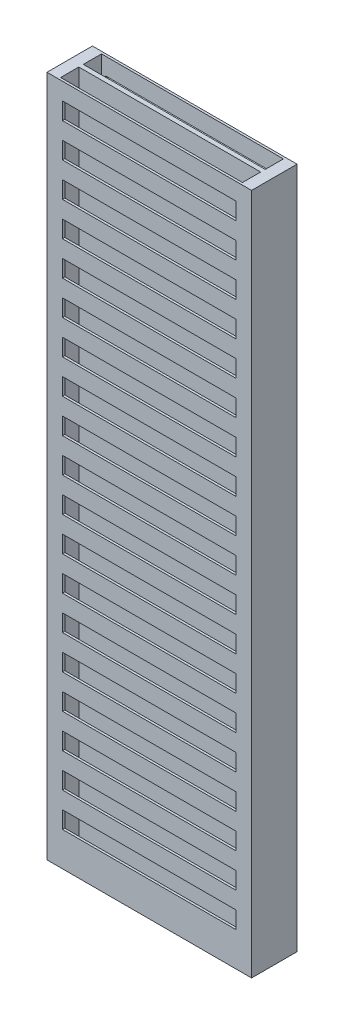
from build123d import *

# Parameters (mm, degrees)
SKETCH1_W                = 9
SKETCH1_H                = 2
BOSS_EXTRUDE1_DEPTH      = 15
CUT_EXTRUDE1_START       = -31
SKETCH2_W                = 8
SKETCH2_H                = 0.8
CUT_EXTRUDE1_DEPTH       = 32
SKETCH3_W                = 7.634272068
SKETCH3_H                = 0.75
CUT_EXTRUDE2_DEPTH       = 0.1
LPATTERN1_COUNT          = 19
LPATTERN1_PITCH          = 1.5
MIRROR2_COPY_1_SKETCH_W  = 7.634272068
MIRROR2_COPY_1_SKETCH_H  = 0.75
MIRROR2_COPY_1_DEPTH     = 0.1
MIRROR2_COPY_2_SKETCH_W  = 7.634272068
MIRROR2_COPY_2_SKETCH_H  = 0.75
MIRROR2_COPY_2_DEPTH     = 0.1
MIRROR2_COPY_3_SKETCH_W  = 7.634272068
MIRROR2_COPY_3_SKETCH_H  = 0.75
MIRROR2_COPY_3_DEPTH     = 0.1
MIRROR2_COPY_4_SKETCH_W  = 7.634272068
MIRROR2_COPY_4_SKETCH_H  = 0.75
MIRROR2_COPY_4_DEPTH     = 0.1
MIRROR2_COPY_5_SKETCH_W  = 7.634272068
MIRROR2_COPY_5_SKETCH_H  = 0.75
MIRROR2_COPY_5_DEPTH     = 0.1
MIRROR2_COPY_6_SKETCH_W  = 7.634272068
MIRROR2_COPY_6_SKETCH_H  = 0.75
MIRROR2_COPY_6_DEPTH     = 0.1
MIRROR2_COPY_7_SKETCH_W  = 7.634272068
MIRROR2_COPY_7_SKETCH_H  = 0.75
MIRROR2_COPY_7_DEPTH     = 0.1
MIRROR2_COPY_8_SKETCH_W  = 7.634272068
MIRROR2_COPY_8_SKETCH_H  = 0.75
MIRROR2_COPY_8_DEPTH     = 0.1
MIRROR2_COPY_9_SKETCH_W  = 7.634272068
MIRROR2_COPY_9_SKETCH_H  = 0.75
MIRROR2_COPY_9_DEPTH     = 0.1
MIRROR2_COPY_10_SKETCH_W = 7.634272068
MIRROR2_COPY_10_SKETCH_H = 0.75
MIRROR2_COPY_10_DEPTH    = 0.1
MIRROR2_COPY_11_SKETCH_W = 7.634272068
MIRROR2_COPY_11_SKETCH_H = 0.75
MIRROR2_COPY_11_DEPTH    = 0.1
MIRROR2_COPY_12_SKETCH_W = 7.634272068
MIRROR2_COPY_12_SKETCH_H = 0.75
MIRROR2_COPY_12_DEPTH    = 0.1
MIRROR2_COPY_13_SKETCH_W = 7.634272068
MIRROR2_COPY_13_SKETCH_H = 0.75
MIRROR2_COPY_13_DEPTH    = 0.1
MIRROR2_COPY_14_SKETCH_W = 7.634272068
MIRROR2_COPY_14_SKETCH_H = 0.75
MIRROR2_COPY_14_DEPTH    = 0.1
MIRROR2_COPY_15_SKETCH_W = 7.634272068
MIRROR2_COPY_15_SKETCH_H = 0.75
MIRROR2_COPY_15_DEPTH    = 0.1
MIRROR2_COPY_16_SKETCH_W = 7.634272068
MIRROR2_COPY_16_SKETCH_H = 0.75
MIRROR2_COPY_16_DEPTH    = 0.1
MIRROR2_COPY_17_SKETCH_W = 7.634272068
MIRROR2_COPY_17_SKETCH_H = 0.75
MIRROR2_COPY_17_DEPTH    = 0.1
MIRROR2_COPY_18_SKETCH_W = 7.634272068
MIRROR2_COPY_18_SKETCH_H = 0.75
MIRROR2_COPY_18_DEPTH    = 0.1


with BuildPart() as part:
    # Sketch1 → Boss-Extrude1 (new body, symmetric)
    with BuildSketch(Plane(origin=(0, 0, 0), x_dir=(1, 0, 0), z_dir=(0, 1, 0))):
        Rectangle(SKETCH1_W, SKETCH1_H)
    extrude(amount=BOSS_EXTRUDE1_DEPTH, both=True)

    # Sketch2 → Cut-Extrude1 (cut)
    with BuildSketch(Plane(origin=(0, 15, 0), x_dir=(1, 0, 0), z_dir=(0, 1, 0)).offset(CUT_EXTRUDE1_START)):
        with Locations((0, 0.5)):
            Rectangle(SKETCH2_W, SKETCH2_H)
    cut_extrude1 = extrude(amount=CUT_EXTRUDE1_DEPTH, mode=Mode.SUBTRACT)

    # Mirror1: Cut-Extrude1 across plane
    add(cut_extrude1.mirror(Plane.XY), mode=Mode.SUBTRACT)

    # Sketch3 → Cut-Extrude2 (cut)
    with BuildSketch(Plane.XY.offset(1)):
        with Locations((0, 13.875)):
            Rectangle(SKETCH3_W, SKETCH3_H)
    cut_extrude2 = extrude(amount=-CUT_EXTRUDE2_DEPTH, mode=Mode.SUBTRACT)

    # LPattern1: Cut-Extrude2 ×19
    with Locations(*[(0, -i * LPATTERN1_PITCH, 0) for i in range(1, LPATTERN1_COUNT)]):
        add(cut_extrude2, mode=Mode.SUBTRACT)

    # Mirror2: Cut-Extrude2 across plane
    add(cut_extrude2.mirror(Plane.XY), mode=Mode.SUBTRACT)

    # Mirror2 copy 1 sketch → Mirror2 copy 1 (cut)
    with BuildSketch(Plane(origin=(0, -1.5, -1), x_dir=(1, 0, 0), z_dir=(0, 0, -1))):
        with Locations((0, -13.875)):
            Rectangle(MIRROR2_COPY_1_SKETCH_W, MIRROR2_COPY_1_SKETCH_H)
    extrude(amount=-MIRROR2_COPY_1_DEPTH, mode=Mode.SUBTRACT)

    # Mirror2 copy 2 sketch → Mirror2 copy 2 (cut)
    with BuildSketch(Plane(origin=(0, -3, -1), x_dir=(1, 0, 0), z_dir=(0, 0, -1))):
        with Locations((0, -13.875)):
            Rectangle(MIRROR2_COPY_2_SKETCH_W, MIRROR2_COPY_2_SKETCH_H)
    extrude(amount=-MIRROR2_COPY_2_DEPTH, mode=Mode.SUBTRACT)

    # Mirror2 copy 3 sketch → Mirror2 copy 3 (cut)
    with BuildSketch(Plane(origin=(0, -4.5, -1), x_dir=(1, 0, 0), z_dir=(0, 0, -1))):
        with Locations((0, -13.875)):
            Rectangle(MIRROR2_COPY_3_SKETCH_W, MIRROR2_COPY_3_SKETCH_H)
    extrude(amount=-MIRROR2_COPY_3_DEPTH, mode=Mode.SUBTRACT)

    # Mirror2 copy 4 sketch → Mirror2 copy 4 (cut)
    with BuildSketch(Plane(origin=(0, -6, -1), x_dir=(1, 0, 0), z_dir=(0, 0, -1))):
        with Locations((0, -13.875)):
            Rectangle(MIRROR2_COPY_4_SKETCH_W, MIRROR2_COPY_4_SKETCH_H)
    extrude(amount=-MIRROR2_COPY_4_DEPTH, mode=Mode.SUBTRACT)

    # Mirror2 copy 5 sketch → Mirror2 copy 5 (cut)
    with BuildSketch(Plane(origin=(0, -7.5, -1), x_dir=(1, 0, 0), z_dir=(0, 0, -1))):
        with Locations((0, -13.875)):
            Rectangle(MIRROR2_COPY_5_SKETCH_W, MIRROR2_COPY_5_SKETCH_H)
    extrude(amount=-MIRROR2_COPY_5_DEPTH, mode=Mode.SUBTRACT)

    # Mirror2 copy 6 sketch → Mirror2 copy 6 (cut)
    with BuildSketch(Plane(origin=(0, -9, -1), x_dir=(1, 0, 0), z_dir=(0, 0, -1))):
        with Locations((0, -13.875)):
            Rectangle(MIRROR2_COPY_6_SKETCH_W, MIRROR2_COPY_6_SKETCH_H)
    extrude(amount=-MIRROR2_COPY_6_DEPTH, mode=Mode.SUBTRACT)

    # Mirror2 copy 7 sketch → Mirror2 copy 7 (cut)
    with BuildSketch(Plane(origin=(0, -10.5, -1), x_dir=(1, 0, 0), z_dir=(0, 0, -1))):
        with Locations((0, -13.875)):
            Rectangle(MIRROR2_COPY_7_SKETCH_W, MIRROR2_COPY_7_SKETCH_H)
    extrude(amount=-MIRROR2_COPY_7_DEPTH, mode=Mode.SUBTRACT)

    # Mirror2 copy 8 sketch → Mirror2 copy 8 (cut)
    with BuildSketch(Plane(origin=(0, -12, -1), x_dir=(1, 0, 0), z_dir=(0, 0, -1))):
        with Locations((0, -13.875)):
            Rectangle(MIRROR2_COPY_8_SKETCH_W, MIRROR2_COPY_8_SKETCH_H)
    extrude(amount=-MIRROR2_COPY_8_DEPTH, mode=Mode.SUBTRACT)

    # Mirror2 copy 9 sketch → Mirror2 copy 9 (cut)
    with BuildSketch(Plane(origin=(0, -13.5, -1), x_dir=(1, 0, 0), z_dir=(0, 0, -1))):
        with Locations((0, -13.875)):
            Rectangle(MIRROR2_COPY_9_SKETCH_W, MIRROR2_COPY_9_SKETCH_H)
    extrude(amount=-MIRROR2_COPY_9_DEPTH, mode=Mode.SUBTRACT)

    # Mirror2 copy 10 sketch → Mirror2 copy 10 (cut)
    with BuildSketch(Plane(origin=(0, -15, -1), x_dir=(1, 0, 0), z_dir=(0, 0, -1))):
        with Locations((0, -13.875)):
            Rectangle(MIRROR2_COPY_10_SKETCH_W, MIRROR2_COPY_10_SKETCH_H)
    extrude(amount=-MIRROR2_COPY_10_DEPTH, mode=Mode.SUBTRACT)

    # Mirror2 copy 11 sketch → Mirror2 copy 11 (cut)
    with BuildSketch(Plane(origin=(0, -16.5, -1), x_dir=(1, 0, 0), z_dir=(0, 0, -1))):
        with Locations((0, -13.875)):
            Rectangle(MIRROR2_COPY_11_SKETCH_W, MIRROR2_COPY_11_SKETCH_H)
    extrude(amount=-MIRROR2_COPY_11_DEPTH, mode=Mode.SUBTRACT)

    # Mirror2 copy 12 sketch → Mirror2 copy 12 (cut)
    with BuildSketch(Plane(origin=(0, -18, -1), x_dir=(1, 0, 0), z_dir=(0, 0, -1))):
        with Locations((0, -13.875)):
            Rectangle(MIRROR2_COPY_12_SKETCH_W, MIRROR2_COPY_12_SKETCH_H)
    extrude(amount=-MIRROR2_COPY_12_DEPTH, mode=Mode.SUBTRACT)

    # Mirror2 copy 13 sketch → Mirror2 copy 13 (cut)
    with BuildSketch(Plane(origin=(0, -19.5, -1), x_dir=(1, 0, 0), z_dir=(0, 0, -1))):
        with Locations((0, -13.875)):
            Rectangle(MIRROR2_COPY_13_SKETCH_W, MIRROR2_COPY_13_SKETCH_H)
    extrude(amount=-MIRROR2_COPY_13_DEPTH, mode=Mode.SUBTRACT)

    # Mirror2 copy 14 sketch → Mirror2 copy 14 (cut)
    with BuildSketch(Plane(origin=(0, -21, -1), x_dir=(1, 0, 0), z_dir=(0, 0, -1))):
        with Locations((0, -13.875)):
            Rectangle(MIRROR2_COPY_14_SKETCH_W, MIRROR2_COPY_14_SKETCH_H)
    extrude(amount=-MIRROR2_COPY_14_DEPTH, mode=Mode.SUBTRACT)

    # Mirror2 copy 15 sketch → Mirror2 copy 15 (cut)
    with BuildSketch(Plane(origin=(0, -22.5, -1), x_dir=(1, 0, 0), z_dir=(0, 0, -1))):
        with Locations((0, -13.875)):
            Rectangle(MIRROR2_COPY_15_SKETCH_W, MIRROR2_COPY_15_SKETCH_H)
    extrude(amount=-MIRROR2_COPY_15_DEPTH, mode=Mode.SUBTRACT)

    # Mirror2 copy 16 sketch → Mirror2 copy 16 (cut)
    with BuildSketch(Plane(origin=(0, -24, -1), x_dir=(1, 0, 0), z_dir=(0, 0, -1))):
        with Locations((0, -13.875)):
            Rectangle(MIRROR2_COPY_16_SKETCH_W, MIRROR2_COPY_16_SKETCH_H)
    extrude(amount=-MIRROR2_COPY_16_DEPTH, mode=Mode.SUBTRACT)

    # Mirror2 copy 17 sketch → Mirror2 copy 17 (cut)
    with BuildSketch(Plane(origin=(0, -25.5, -1), x_dir=(1, 0, 0), z_dir=(0, 0, -1))):
        with Locations((0, -13.875)):
            Rectangle(MIRROR2_COPY_17_SKETCH_W, MIRROR2_COPY_17_SKETCH_H)
    extrude(amount=-MIRROR2_COPY_17_DEPTH, mode=Mode.SUBTRACT)

    # Mirror2 copy 18 sketch → Mirror2 copy 18 (cut)
    with BuildSketch(Plane(origin=(0, -27, -1), x_dir=(1, 0, 0), z_dir=(0, 0, -1))):
        with Locations((0, -13.875)):
            Rectangle(MIRROR2_COPY_18_SKETCH_W, MIRROR2_COPY_18_SKETCH_H)
    extrude(amount=-MIRROR2_COPY_18_DEPTH, mode=Mode.SUBTRACT)


solid = part.part
